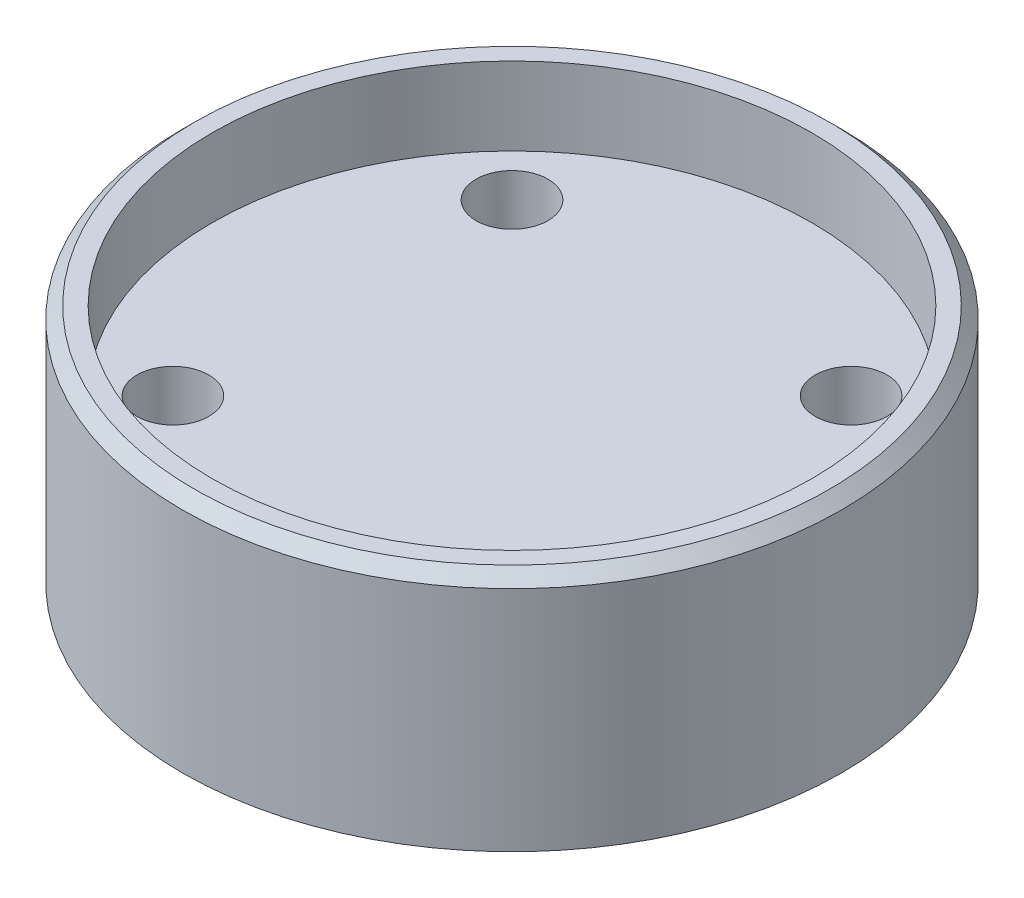
from build123d import *

# Parameters (mm, degrees)
SKETCH2_R               = 3
CUT_EXTRUDE2_DEPTH      = 21
CUT_EXTRUDE2_DEPTH_BACK = 1
CHAMFER1_SIZE           = 1


with BuildPart() as part:
    # Sketch1 → Revolve1 (revolve)
    with BuildSketch(Plane.XY):
        Polygon((27.5, 0), (27.5, 20), (25, 20), (25, 13.5), (0, 13.5), (0, 0), align=None)
    revolve(axis=Axis((0, -626.687351978, 0), (0, 1, 0)))

    # Sketch2 → Cut-Extrude2 (cut, two sides)
    with BuildSketch(Plane(origin=(0, 0, 0), x_dir=(1, 0, 0), z_dir=(0, 1, 0))) as cut_extrude2_sk:
        with Locations((-14.142135624, 14.142135624)):
            Circle(SKETCH2_R)
        with Locations((14.142135624, 14.142135624)):
            Circle(SKETCH2_R)
        with Locations((14.142135624, -14.142135624)):
            Circle(SKETCH2_R)
        with Locations((-14.142135624, -14.142135624)):
            Circle(SKETCH2_R)
    extrude(amount=CUT_EXTRUDE2_DEPTH, mode=Mode.SUBTRACT)
    extrude(cut_extrude2_sk.sketch, amount=-CUT_EXTRUDE2_DEPTH_BACK, mode=Mode.SUBTRACT)

    # Chamfer1
    chamfer1_edges = [part.edges().sort_by_distance(p)[0] for p in [
        (-27.5, 20, 0),
    ]]
    chamfer(chamfer1_edges, length=CHAMFER1_SIZE)


solid = part.part
